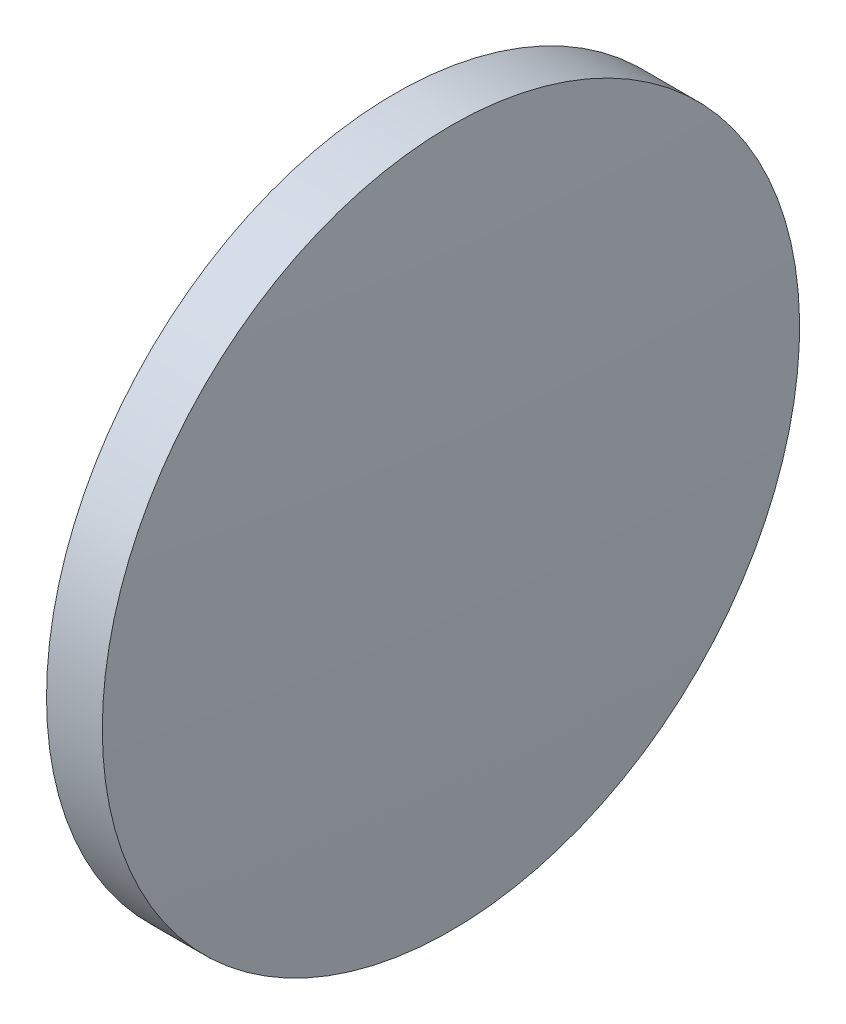
from build123d import *


with BuildPart() as part:
    # 草图1 → 旋转1 (revolve)
    with BuildSketch(Plane.XY):
        with BuildLine():
            Line((694.193887129, 53.941990217), (694.193887129, 66.441990217))
            Line((694.193887129, 66.441990217), (696.193887129, 66.441990217))
            ThreePointArc((696.193887129, 66.441990217), (696.47886519, 60.19487755), (696.573887129, 53.941990217))
            Line((696.573887129, 53.941990217), (694.193887129, 53.941990217))
        make_face()
    revolve(axis=Axis((692.164779551, 53.941990217, 0), (1, 0, 0)))


solid = part.part
